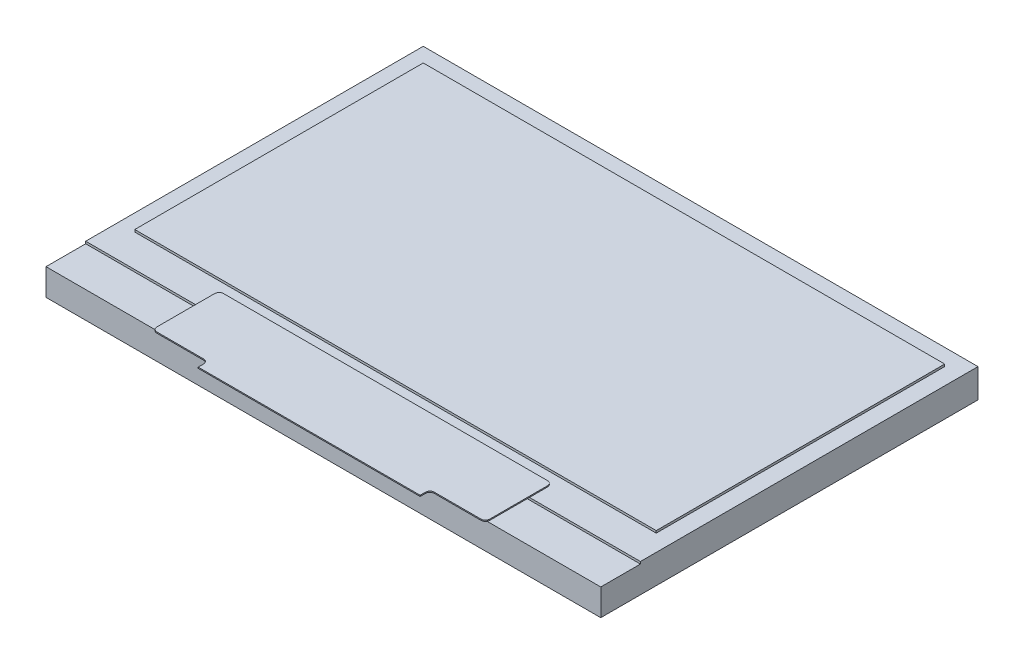
from build123d import *

# Parameters (mm, degrees)
SKETCH3_W           = 25
SKETCH3_H           = 17
BOSS_EXTRUDE3_DEPTH = 1.3
SKETCH4_W           = 4.047255343
SKETCH4_H           = 0.65
CUT_EXTRUDE1_DEPTH  = 30.3
SKETCH6_W           = 23.5
SKETCH6_H           = 13
BOSS_EXTRUDE4_DEPTH = 0.1
BOSS_EXTRUDE6_DEPTH = 0.05


with BuildPart() as part:
    # Sketch3 → Boss-Extrude3 (new body)
    with BuildSketch(Plane(origin=(0, 0, 0), x_dir=(1, 0, 0), z_dir=(0, 1, 0))):
        with Locations((0, -12.92)):
            Rectangle(SKETCH3_W, SKETCH3_H)
    extrude(amount=BOSS_EXTRUDE3_DEPTH)

    # Sketch4 → Cut-Extrude1 (cut)
    with BuildSketch(Plane.ZY.offset(12.5)):
        with Locations((21.656372328, 1.525)):
            Rectangle(SKETCH4_W, SKETCH4_H)
    extrude(amount=-CUT_EXTRUDE1_DEPTH, mode=Mode.SUBTRACT)

    # Sketch6 → Boss-Extrude4 (add)
    with BuildSketch(Plane(origin=(0, 1.3, 0), x_dir=(1, 0, 0), z_dir=(0, 1, 0))):
        with Locations((0, -11.67)):
            Rectangle(SKETCH6_W, SKETCH6_H)
    extrude(amount=BOSS_EXTRUDE4_DEPTH)

    # Sketch10 → Boss-Extrude6 (add)
    with BuildSketch(Plane(origin=(0, 1.3, 0), x_dir=(1, 0, 0), z_dir=(0, 1, 0))):
        with BuildLine():
            Line((-5, -21.82), (-5, -22.06))
            Line((-5, -22.06), (5, -22.06))
            Line((5, -22.06), (5, -21.82))
            ThreePointArc((5, -21.82), (5.058578644, -21.678578644), (5.2, -21.62))
            Line((5.2, -21.62), (7.3, -21.62))
            ThreePointArc((7.3, -21.62), (7.441421356, -21.561421356), (7.5, -21.42))
            Line((7.5, -21.42), (7.5, -18.82))
            ThreePointArc((7.5, -18.82), (7.441421356, -18.678578644), (7.3, -18.62))
            Line((7.3, -18.62), (-7.3, -18.62))
            ThreePointArc((-7.3, -18.62), (-7.441421356, -18.678578644), (-7.5, -18.82))
            Line((-7.5, -18.82), (-7.5, -21.42))
            ThreePointArc((-7.5, -21.42), (-7.441421356, -21.561421356), (-7.3, -21.62))
            Line((-7.3, -21.62), (-5.2, -21.62))
            ThreePointArc((-5.2, -21.62), (-5.058578644, -21.678578644), (-5, -21.82))
        make_face()
    extrude(amount=BOSS_EXTRUDE6_DEPTH)


solid = part.part
